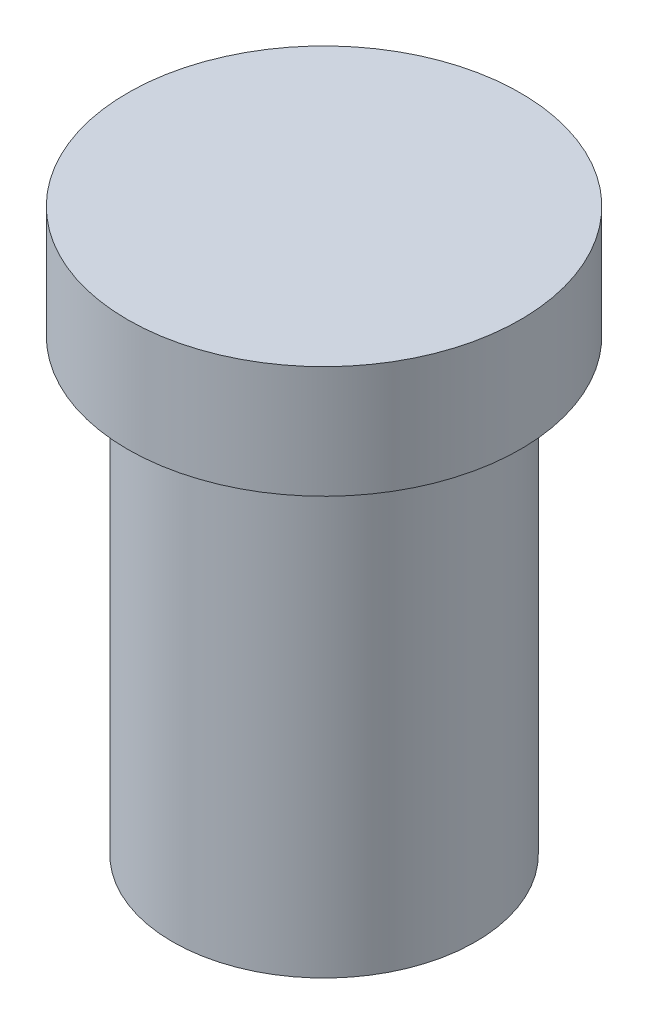
from build123d import *

# Parameters (mm, degrees)
SKETCH1_R      = 6.75
EXTRUDE1_DEPTH = 20
SKETCH2_R      = 8.75
EXTRUDE2_DEPTH = 5


with BuildPart() as part:
    # Sketch1 → Extrude1 (new body)
    with BuildSketch(Plane(origin=(0, 0, 0), x_dir=(1, 0, 0), z_dir=(0, 1, 0))):
        with Locations(Location((0, 0, 0), (0, 0, 270))):  # turned: the seam where the file's is
            Circle(SKETCH1_R)
    extrude(amount=-EXTRUDE1_DEPTH)

    # Sketch2 → Extrude2 (add)
    with BuildSketch(Plane(origin=(0, 0, 0), x_dir=(1, 0, 0), z_dir=(0, 1, 0))):
        with Locations(Location((0, 0, 0), (0, 0, 270))):  # turned: the seam where the file's is
            Circle(SKETCH2_R)
    extrude(amount=EXTRUDE2_DEPTH)


solid = part.part
